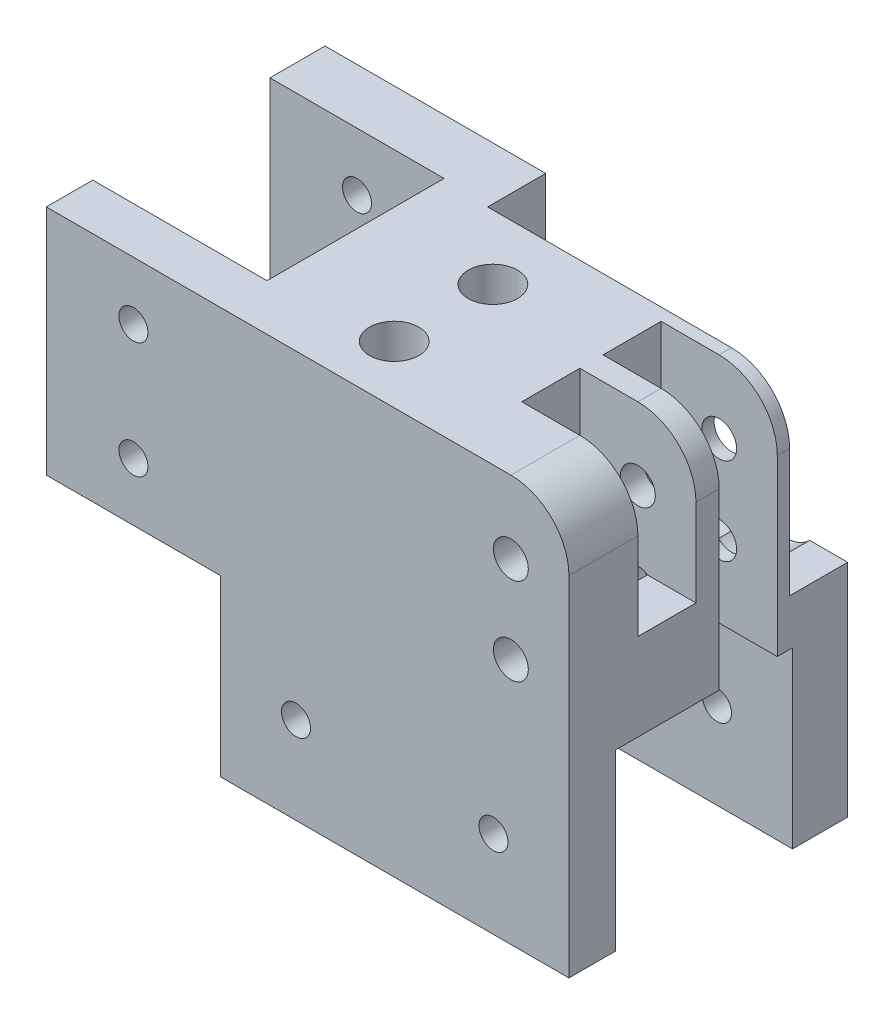
from build123d import *

# Parameters (mm, degrees)
RESSALTO_EXTRUS_O1_DEPTH                   = 8
BROCA_DE_ROSQUEAR_PARA_TARRAXA_DE_M6X1_0_D = 5
RESSALTO_EXTRUS_O2_DEPTH                   = 30
ESBO_O6_W                                  = 10
ESBO_O6_H                                  = 40
ESBO_O6_H_2                                = 25
CORTE_EXTRUS_O2_DEPTH                      = 20
ESBO_O14_R                                 = 3
CORTE_EXTRUS_O6_DEPTH                      = 39
ESBO_O15_R                                 = 4.25
CORTE_EXTRUS_O7_DEPTH                      = 40
RESSALTO_EXTRUS_O3_DEPTH                   = 10
ESBO_O17_W                                 = 9.5
ESBO_O17_H                                 = 40
RESSALTO_EXTRUS_O4_DEPTH                   = 30
ESBO_O18_R                                 = 2.5
CORTE_EXTRUS_O8_DEPTH                      = 10
ESBO_O19_W                                 = 60
ESBO_O19_H                                 = 9.5
RESSALTO_EXTRUS_O5_DEPTH                   = 30
FILETE1_R                                  = 5
ESBO_O20_R                                 = 2.5
CORTE_EXTRUS_O9_DEPTH                      = 10


with BuildPart() as part:
    # Esboço1 → Ressalto-extrusão1 (new body)
    with BuildSketch(Plane.XY):
        with BuildLine():
            Line((440, 72.212171493), (380, 72.212171493))
            Line((380, 72.212171493), (380, 132.212171493))
            ThreePointArc((380, 132.212171493), (382.928932188, 139.283239304), (390, 142.212171493))
            Line((390, 142.212171493), (470, 142.212171493))
            Line((470, 142.212171493), (470, 102.212171493))
            Line((470, 102.212171493), (440, 102.212171493))
            Line((440, 102.212171493), (440, 72.212171493))
        make_face()
    extrude(amount=RESSALTO_EXTRUS_O1_DEPTH)

    # Broca de rosquear para tarraxa de M6x1.01 (through all)
    with Locations(Plane.XY.offset(8)):
        with Locations((393, 87.212171493), (427, 87.212171493), (455, 112.212171493), (455, 132.212171493)):
            Hole(BROCA_DE_ROSQUEAR_PARA_TARRAXA_DE_M6X1_0_D / 2)

    # Esboço4 → Ressalto-extrusão2 (add)
    with BuildSketch(Plane(origin=(0, 0, 0), x_dir=(-1, 0, 0), z_dir=(0, 0, -1))):
        with BuildLine():
            Line((-390, 142.212171493), (-440, 142.212171493))
            Line((-440, 142.212171493), (-440, 102.212171493))
            Line((-440, 102.212171493), (-380, 102.212171493))
            Line((-380, 102.212171493), (-380, 132.212171493))
            ThreePointArc((-380, 132.212171493), (-382.928932188, 139.283239304), (-390, 142.212171493))
        make_face()
    extrude(amount=RESSALTO_EXTRUS_O2_DEPTH)

    # Esboço6 → Corte-extrusão2 (cut)
    with BuildSketch(Plane.ZY.offset(-380)):
        with Locations((-22.874860756, 122.212171493)):
            Rectangle(ESBO_O6_W, ESBO_O6_H)
        with Locations((-8.874860756, 129.712171493)):
            Rectangle(ESBO_O6_W, ESBO_O6_H_2)
    extrude(amount=-CORTE_EXTRUS_O2_DEPTH, mode=Mode.SUBTRACT)

    # Esboço14 → Corte-extrusão6 (cut, through all)
    with BuildSketch(Plane(origin=(0, 0, -30), x_dir=(-1, 0, 0), z_dir=(0, 0, -1))):
        with Locations((-390, 129.712171493)):
            Circle(ESBO_O14_R)
        with Locations((-390, 114.712171493)):
            Circle(ESBO_O14_R)
    extrude(amount=-CORTE_EXTRUS_O6_DEPTH, mode=Mode.SUBTRACT)

    # Esboço15 → Corte-extrusão7 (cut)
    with BuildSketch(Plane(origin=(0, 142.212171493, 0), x_dir=(1, 0, 0), z_dir=(0, 1, 0))):
        with Locations((420, 18.90241208)):
            Circle(ESBO_O15_R)
        with Locations((420, 1.90241208)):
            Circle(ESBO_O15_R)
    extrude(amount=-CORTE_EXTRUS_O7_DEPTH, mode=Mode.SUBTRACT)


with BuildPart() as body_2:
    # Espelhar1: mirrored copy
    add(part.part.mirror(Plane(origin=(380, 72.212171493, 8), x_dir=(0, 0, 1), z_dir=(-1, 0, 0))))

    # Esboço16 → Ressalto-extrusão3 (add)
    with BuildSketch(Plane(origin=(0, 0, -30), x_dir=(-1, 0, 0), z_dir=(0, 0, -1))):
        with BuildLine():
            Line((-320, 142.212171493), (-328, 142.212171493))
            Line((-328, 142.212171493), (-328, 110.212171493))
            Line((-328, 110.212171493), (-365.320990692, 110.212171493))
            ThreePointArc((-365.320990692, 110.212171493), (-369.387979043, 108.52756976), (-373.454967393, 110.212171493))
            Line((-373.454967393, 110.212171493), (-380, 110.212171493))
            Line((-380, 110.212171493), (-380, 102.212171493))
            Line((-380, 102.212171493), (-328, 102.212171493))
            Line((-328, 102.212171493), (-320, 102.212171493))
            Line((-320, 102.212171493), (-320, 142.212171493))
        make_face()
    extrude(amount=RESSALTO_EXTRUS_O3_DEPTH)

    # Esboço17 → Ressalto-extrusão4 (add, through all)
    with BuildSketch(Plane.ZY.offset(-320)):
        with Locations((-35.25, 122.212171493)):
            Rectangle(ESBO_O17_W, ESBO_O17_H)
    extrude(amount=RESSALTO_EXTRUS_O4_DEPTH)

    # Esboço18 → Corte-extrusão8 (cut)
    with BuildSketch(Plane.XY.offset(-30.5)):
        with Locations((305, 112.212171493)):
            Circle(ESBO_O18_R)
        with Locations((305, 132.212171493)):
            Circle(ESBO_O18_R)
    extrude(amount=-CORTE_EXTRUS_O8_DEPTH, mode=Mode.SUBTRACT)

    # Esboço19 → Ressalto-extrusão5 (add, through all)
    with BuildSketch(Plane.XZ.offset(-102.212171493)):
        with Locations((350, -35.25)):
            Rectangle(ESBO_O19_W, ESBO_O19_H)
    extrude(amount=RESSALTO_EXTRUS_O5_DEPTH)

    # Filete1
    filete1_edges = [body_2.edges().sort_by_distance(p)[0] for p in [
        (328, 110.212171493, -35),
    ]]
    fillet(filete1_edges, radius=FILETE1_R)

    # Esboço20 → Corte-extrusão9 (cut)
    with BuildSketch(Plane.XY.offset(-30.5)):
        with Locations((367, 87.212171493)):
            Circle(ESBO_O20_R)
        with Locations((333, 87.212171493)):
            Circle(ESBO_O20_R)
    extrude(amount=-CORTE_EXTRUS_O9_DEPTH, mode=Mode.SUBTRACT)


solid = body_2.part
